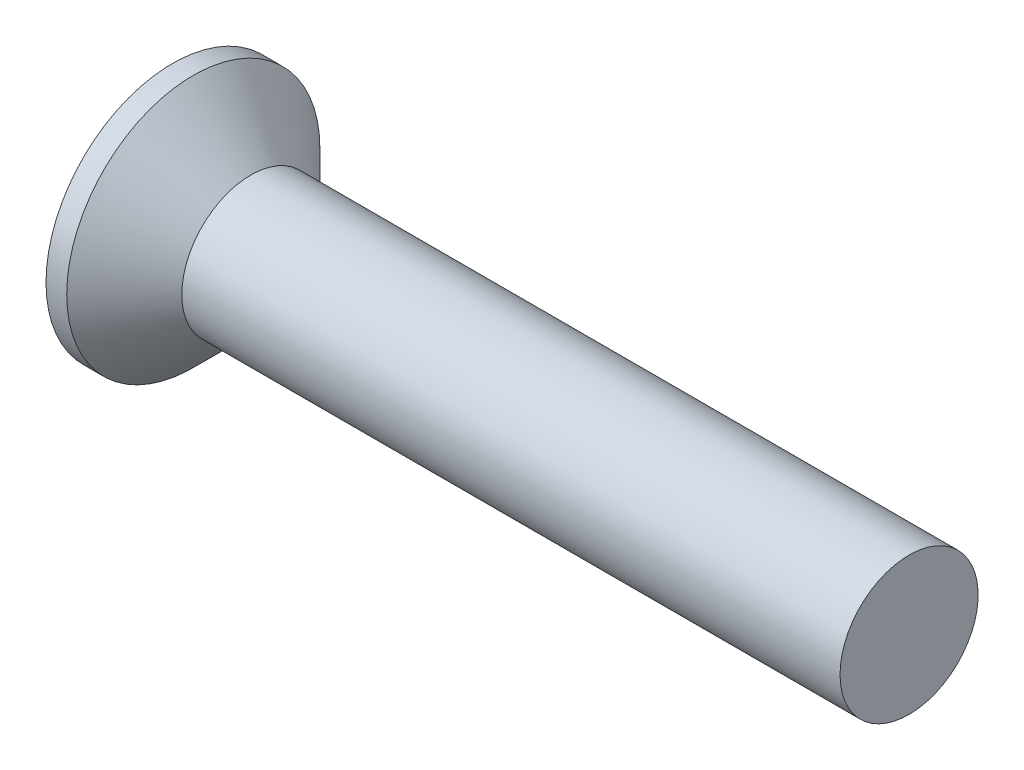
from build123d import *

# Parameters (mm, degrees)
SKETCH3_W         = 0.79
SKETCH3_H         = 3.1
SKETCH4_W         = 0.395
SKETCH4_H         = 0.395
CIRPATTERN1_COUNT = 2
CIRPATTERN1_ANGLE = 90


with BuildPart() as part:
    # BodySke → Base-Revolve (revolve)
    with BuildSketch(Plane.XY):
        Polygon((0, 0), (0, 2.75), (0.45, 2.75), (1.7, 1.5), (16, 1.5), (16, 0), align=None)
    revolve(axis=Axis((-6.35, 0, 0), (1, 0, 0)))

    # Sketch3 → Cross section 0
    with BuildSketch(Plane.ZY):
        Rectangle(SKETCH3_W, SKETCH3_H)
    # Sketch4 → Cross section 1
    with BuildSketch(Plane.ZY.offset(-2.08)):
        Rectangle(SKETCH4_W, SKETCH4_H)
    cross = loft(mode=Mode.SUBTRACT)

    # CirPattern1: Cross ×2 about axis
    cirpattern1_axis = Axis((0, 0, 0), (1, 0, 0))
    for i in range(1, CIRPATTERN1_COUNT):
        add(cross.rotate(cirpattern1_axis, i * CIRPATTERN1_ANGLE / (CIRPATTERN1_COUNT - 1)), mode=Mode.SUBTRACT)


solid = part.part
